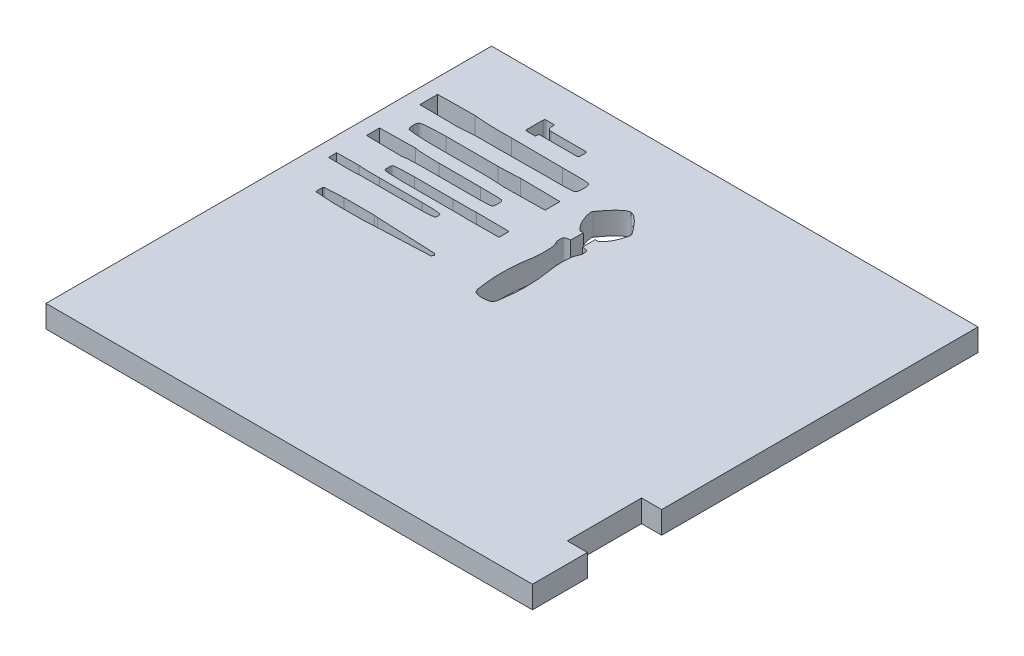
from build123d import *

# Parameters (mm, degrees)
SKICA1_W                 = 655
SKICA1_H                 = 600
P_IDAT_VYSUNUT_M1_DEPTH  = 30
SKICA3_W                 = 54.082765628
SKICA3_H                 = 100
KONTROLA_100_DEPTH       = 31
ODEBRAT_VYSUNUT_M1_DEPTH = 31
SEKACE_DEPTH             = 31.0000001


with BuildPart() as part:
    # Skica1 → Přidat vysunutím1 (new body)
    with BuildSketch(Plane(origin=(0, 0, 0), x_dir=(1, 0, 0), z_dir=(0, 1, 0))):
        Rectangle(SKICA1_W, SKICA1_H)
    extrude(amount=P_IDAT_VYSUNUT_M1_DEPTH)

    # Skica3 → KONTROLA_100 (cut, through all)
    with BuildSketch(Plane(origin=(0, 30, 0), x_dir=(1, 0, 0), z_dir=(0, 1, 0))):
        with Locations((327.5, -175.970044555)):
            Rectangle(SKICA3_W, SKICA3_H)
    extrude(amount=-KONTROLA_100_DEPTH, mode=Mode.SUBTRACT)

    # Skica4 → Odebrat vysunutím1 (cut, through all)
    with BuildSketch(Plane(origin=(0, 30, 0), x_dir=(1, 0, 0), z_dir=(0, 1, 0))):
        with BuildLine():
            Line((-192.848768769, 245.152749842), (-193.232573401, 250.450660731))
            Line((-193.232573401, 250.450660731), (-204.547490515, 250.450660731))
            ThreePointArc((-204.547490515, 250.450660731), (-205.961704077, 249.864874293), (-206.547490515, 248.450660731))
            Line((-206.547490515, 248.450660731), (-206.547490515, 226.450660731))
            ThreePointArc((-206.547490515, 226.450660731), (-205.961704077, 225.036447168), (-204.547490515, 224.450660731))
            Line((-204.547490515, 224.450660731), (-193.239817853, 224.450660731))
            Line((-193.239817853, 224.450660731), (-192.649430044, 228.074810057))
            ThreePointArc((-192.649430044, 228.074810057), (-192.310211907, 228.67586043), (-191.662440489, 228.914025677))
            Line((-191.662440489, 228.914025677), (-141.547490515, 228.914025677))
            ThreePointArc((-141.547490515, 228.914025677), (-140.133276952, 229.499812115), (-139.547490515, 230.914025677))
            Line((-139.547490515, 230.914025677), (-139.547490515, 238.514025677))
            ThreePointArc((-139.547490515, 238.514025677), (-140.133276952, 239.92823924), (-141.547490515, 240.514025677))
            Line((-141.547490515, 240.514025677), (-187.861837872, 240.514025677))
            ThreePointArc((-187.861837872, 240.514025677), (-191.267246865, 241.852988995), (-192.848768769, 245.152749842))
        make_face()
        with BuildLine():
            Line((-48.034805533, 126.818260272), (-48.034805533, 144.024453782))
            Line((-48.034805533, 144.024453782), (-52.534805533, 144.024453782))
            add(Edge.make_bspline(
                [(-52.534805533, 144.024453782), (-56.789361957, 147.681596628), (-60.810249216, 153.578897942), (-63.758899874, 160.548435859), (-66.17143223, 167.249914625), (-66.43949138, 171.270801885), (-67.662912077, 173.386742316), (-63.36084318, 179.518992695), (-60.323127238, 183.519518286), (-56.069166733, 188.562300914), (-52.402960699, 192.554391929), (-48.920064427, 195.571006192), (-45.783712558, 198.048359078), (-44.218127472, 198.865828685), (-42.757145161, 199.448493187), (-41.262630134, 200.024453782), (-40.034805533, 200.024453782)],
                knots=[0, 0, 0, 0, 0.287040646, 0.36174563, 0.417318532, 0.43829661, 0.471451184, 0.527970852, 0.6634257, 0.729020879, 0.795088629, 0.875046582, 0.930973553, 0.962796243, 0.981966174, 1, 1, 1, 1], degree=3))
            add(Edge.make_bspline(
                [(-27.534805533, 144.024453782), (-23.28024911, 147.681596628), (-19.25936185, 153.578897942), (-16.310711193, 160.548435859), (-13.898178837, 167.249914625), (-13.630119686, 171.270801885), (-12.406698989, 173.386742316), (-16.708767886, 179.518992695), (-19.746483828, 183.519518286), (-24.000444333, 188.562300914), (-27.666650367, 192.554391929), (-31.14954664, 195.571006192), (-34.285898508, 198.048359078), (-35.851483594, 198.865828685), (-37.312465906, 199.448493187), (-38.806980932, 200.024453782), (-40.034805533, 200.024453782)],
                knots=[0, 0, 0, 0, 0.287040646, 0.36174563, 0.417318532, 0.43829661, 0.471451184, 0.527970852, 0.6634257, 0.729020879, 0.795088629, 0.875046582, 0.930973553, 0.962796243, 0.981966174, 1, 1, 1, 1], degree=3))
            Line((-27.534805533, 144.024453782), (-32.034805533, 144.024453782))
            Line((-32.034805533, 144.024453782), (-32.034805533, 126.818260272))
            add(Edge.make_bspline(
                [(-40.034805533, 0.024453782), (-35.976200354, -0.069267822), (-31.016533091, 1.330611977), (-29.216834789, 2.41919939), (-26.823159008, 5.220573734), (-25.778403053, 13.102219758), (-24.418012978, 23.808208807), (-23.496224831, 36.678374415), (-23.794838184, 50.569648615), (-24.350993767, 62.887187031), (-26.52570747, 75.75021444), (-28.269214326, 87.373647016), (-28.229626604, 100.241736791), (-27.479464668, 110.266407005), (-23.944342803, 116.714367094), (-23.845823145, 120.668514538), (-23.731584907, 124.639909226), (-25.482847387, 125.635589086), (-27.465428975, 126.612992724), (-31.035028361, 126.865200815), (-31.753621576, 126.828533659), (-32.034805533, 126.818260272)],
                knots=[0, 0, 0, 0, 0.061122155, 0.06523853, 0.079152994, 0.136803937, 0.218949046, 0.31606897, 0.392132497, 0.506227541, 0.569555453, 0.661259712, 0.747779892, 0.836871577, 0.864437331, 0.888074676, 0.92301319, 0.927486047, 0.939519235, 0.972540283, 0.97818806, 0.97818806, 0.97818806, 0.97818806], degree=3))
            add(Edge.make_bspline(
                [(-40.034805533, 0.024453782), (-44.093410713, -0.069267822), (-49.053077975, 1.330611977), (-50.852776278, 2.41919939), (-53.246452059, 5.220573734), (-54.291208014, 13.102219758), (-55.651598088, 23.808208807), (-56.573386235, 36.678374415), (-56.274772882, 50.569648615), (-55.7186173, 62.887187031), (-53.543903596, 75.75021444), (-51.800396741, 87.373647016), (-51.839984463, 100.241736791), (-52.590146398, 110.266407005), (-56.125268263, 116.714367094), (-56.223787922, 120.668514538), (-56.33802616, 124.639909226), (-54.586763679, 125.635589086), (-52.604182092, 126.612992724), (-49.034582706, 126.865200815), (-48.315989491, 126.828533659), (-48.034805533, 126.818260272)],
                knots=[0, 0, 0, 0, 0.061122155, 0.06523853, 0.079152994, 0.136803937, 0.218949046, 0.31606897, 0.392132497, 0.506227541, 0.569555453, 0.661259712, 0.747779892, 0.836871577, 0.864437331, 0.888074676, 0.92301319, 0.927486047, 0.939519235, 0.972540283, 0.97818806, 0.97818806, 0.97818806, 0.97818806], degree=3))
        make_face()
    extrude(amount=-ODEBRAT_VYSUNUT_M1_DEPTH, mode=Mode.SUBTRACT)

    # Skica5 → sekace (cut, through all)
    with BuildSketch(Plane(origin=(0, 30, 0), x_dir=(1, 0, 0), z_dir=(0, 1, 0))):
        with BuildLine():
            Line((-307.5, 183.466765274), (-307.5, 207.466765274))
            Line((-307.5, 207.466765274), (-257.5, 207.966765274))
            add(Edge.make_bspline(
                [(-257.5, 207.966765274), (-256.825170626, 207.973513567), (-246.950522021, 206.764512553), (-227.064372425, 206.19378827), (-216.209974013, 206.354501395), (-213.967763147, 206.418233644), (-206.879336, 206.366765274)],
                knots=[0, 0, 0, 0, 0.125665232, 0.229420079, 0.35147339, 1, 1, 1, 1], degree=3))
            Line((-206.879336, 206.366765274), (-138.017362165, 205.866765274))
            add(Edge.make_bspline(
                [(-138.017362165, 205.866765274), (-133.169322065, 205.831564133), (-122.851497032, 205.849776458), (-114.403692314, 205.944210928), (-105.556283222, 205.527110902), (-101.069687153, 204.772167441), (-100.126636611, 202.640223078), (-99.690880365, 200.248371974), (-99.534870337, 197.955991178), (-99.472580107, 196.514504584), (-99.490820333, 195.466765274)],
                knots=[0, 0, 0, 0, 0.329374562, 0.579022363, 0.753141124, 0.824270148, 0.863456886, 0.895145303, 0.938345002, 1, 1, 1, 1], degree=3))
            add(Edge.make_bspline(
                [(-138.017362165, 185.066765274), (-133.169194271, 185.066765274), (-122.851542303, 185.096224094), (-114.40368493, 184.987285665), (-105.556283854, 185.406593773), (-101.069687099, 186.161348367), (-100.126636619, 188.293309749), (-99.690880362, 190.68515779), (-99.534870338, 192.977539748), (-99.472580107, 194.419025928), (-99.490820333, 195.466765274)],
                knots=[0, 0, 0, 0, 0.329374562, 0.579022363, 0.753141124, 0.824270148, 0.863456886, 0.895145303, 0.938345002, 1, 1, 1, 1], degree=3))
            Line((-138.017362165, 185.066765274), (-206.879336, 184.566765274))
            add(Edge.make_bspline(
                [(-257.5, 182.966765274), (-256.825170626, 182.96001698), (-246.950522021, 184.169017995), (-227.064372425, 184.739742278), (-216.209974013, 184.579029153), (-213.967763147, 184.515296903), (-206.879336, 184.566765274)],
                knots=[0, 0, 0, 0, 0.125665232, 0.229420079, 0.35147339, 1, 1, 1, 1], degree=3))
            Line((-257.5, 182.966765274), (-307.5, 183.466765274))
        make_face()
        with BuildLine():
            Line((-183.297177135, 145.138303204), (-253.1807847, 145.138303204))
            add(Edge.make_bspline(
                [(-253.1807847, 145.138303204), (-257.558680308, 145.138303204), (-266.875520035, 145.510894763), (-274.667851406, 145.781636134), (-282.349634131, 146.738047815), (-285.690593405, 147.134730067), (-286.731220064, 148.387412028), (-287.724289224, 150.296263597), (-287.930474819, 152.350246305), (-287.860553511, 153.504931237), (-287.970251974, 154.638303204)],
                knots=[0, 0, 0, 0, 0.329374562, 0.579022363, 0.753141124, 0.824270148, 0.863456886, 0.895145303, 0.938345002, 1, 1, 1, 1], degree=3))
            add(Edge.make_bspline(
                [(-253.1807847, 164.138303204), (-257.558680308, 164.138303204), (-266.875520035, 163.765711645), (-274.667851406, 163.494970275), (-282.349634131, 162.538558594), (-285.690593405, 162.141876342), (-286.731220064, 160.88919438), (-287.724289224, 158.980342812), (-287.930474819, 156.926360103), (-287.860553511, 155.771675172), (-287.970251974, 154.638303204)],
                knots=[0, 0, 0, 0, 0.329374562, 0.579022363, 0.753141124, 0.824270148, 0.863456886, 0.895145303, 0.938345002, 1, 1, 1, 1], degree=3))
            Line((-253.1807847, 164.138303204), (-183.297177135, 164.138303204))
            add(Edge.make_bspline(
                [(-153.840717735, 165.388303204), (-156.381018857, 165.42378045), (-158.152236711, 164.94571804), (-166.248765598, 164.647022936), (-173.508871514, 164.24758879), (-178.168829322, 164.138303204), (-183.297177135, 164.138303204)],
                knots=[0, 0, 0, 0, 0.194961343, 0.326122465, 0.480415491, 1, 1, 1, 1], degree=3))
            Line((-153.840717735, 165.388303204), (-100.137962735, 164.638303204))
            Line((-100.137962735, 164.638303204), (-100.137962735, 144.638303204))
            Line((-100.137962735, 144.638303204), (-153.840717735, 143.888303204))
            add(Edge.make_bspline(
                [(-153.840717735, 143.888303204), (-156.381018857, 143.852825958), (-158.152236711, 144.330888369), (-166.248765598, 144.629583473), (-173.508871514, 145.029017619), (-178.168829322, 145.138303204), (-183.297177135, 145.138303204)],
                knots=[0, 0, 0, 0, 0.194961343, 0.326122465, 0.480415491, 1, 1, 1, 1], degree=3))
        make_face()
        with BuildLine():
            Line((-307.5, 111.637488957), (-307.5, 129.137488957))
            Line((-307.5, 129.137488957), (-259.5, 129.887488957))
            add(Edge.make_bspline(
                [(-259.5, 129.887488957), (-258.954393264, 129.897610162), (-256.387499572, 128.910341649), (-243.039415144, 128.445482987), (-235.468859797, 128.179849466), (-231.583969553, 128.146645276), (-226.137193305, 128.137488957)],
                knots=[0, 0, 0, 0, 0.125665232, 0.229420079, 0.35147339, 1, 1, 1, 1], degree=3))
            Line((-226.137193305, 128.137488957), (-170.453291679, 128.137488957))
            add(Edge.make_bspline(
                [(-170.453291679, 128.137488957), (-166.533017936, 128.137488957), (-158.101012388, 128.033226209), (-152.363390211, 127.988720018), (-144.443726456, 127.822186471), (-141.006793572, 127.309661392), (-140.011891948, 126.043422961), (-139.464451132, 124.941428745), (-139.342398212, 122.195238031), (-139.281371751, 123.598846618), (-139.301838676, 120.387488957)],
                knots=[0, 0, 0, 0, 0.329374562, 0.579022363, 0.753141124, 0.824270148, 0.863456886, 0.895145303, 0.938345002, 1, 1, 1, 1], degree=3))
            add(Edge.make_bspline(
                [(-170.453291679, 112.637488957), (-166.533017936, 112.637488957), (-158.101012388, 112.741751704), (-152.363390211, 112.786257896), (-144.443726456, 112.952791443), (-141.006793572, 113.465316522), (-140.011891948, 114.731554953), (-139.464451132, 115.833549169), (-139.342398212, 118.579739883), (-139.281371751, 117.176131296), (-139.301838676, 120.387488957)],
                knots=[0, 0, 0, 0, 0.329374562, 0.579022363, 0.753141124, 0.824270148, 0.863456886, 0.895145303, 0.938345002, 1, 1, 1, 1], degree=3))
            Line((-170.453291679, 112.637488957), (-226.137193305, 112.637488957))
            add(Edge.make_bspline(
                [(-259.5, 110.887488957), (-258.954393264, 110.877367752), (-256.387499572, 111.864636265), (-243.039415144, 112.329494927), (-235.468859797, 112.595128448), (-231.583969553, 112.628332638), (-226.137193305, 112.637488957)],
                knots=[0, 0, 0, 0, 0.125665232, 0.229420079, 0.35147339, 1, 1, 1, 1], degree=3))
            Line((-259.5, 110.887488957), (-307.5, 111.637488957))
        make_face()
        with BuildLine():
            Line((-99.48625027, 95.571644018), (-99.48625027, 82.071644018))
            Line((-99.48625027, 82.071644018), (-144.00481027, 81.671644018))
            add(Edge.make_bspline(
                [(-174.947812595, 82.021644018), (-167.923279872, 82.021644018), (-157.529643524, 81.896565918), (-146.160541985, 82.023738085), (-144.00481027, 81.671644018)],
                knots=[0, 0, 0, 0, 0.667267537, 1, 1, 1, 1], degree=3))
            Line((-174.947812595, 82.021644018), (-226.592960836, 82.021644018))
            add(Edge.make_bspline(
                [(-226.592960836, 82.021644018), (-230.228897125, 82.021644018), (-239.941818795, 82.200339613), (-243.816371479, 82.646648711), (-251.060662681, 82.646383186), (-254.166177225, 83.460134684), (-255.142954432, 84.24960962), (-255.459767915, 85.748739768), (-255.447455062, 87.291333593), (-255.503974584, 86.972861925), (-255.484998953, 88.821644018)],
                knots=[0, 0, 0, 0, 0.329374562, 0.579022363, 0.753141124, 0.824270148, 0.863456886, 0.895145303, 0.938345002, 1, 1, 1, 1], degree=3))
            add(Edge.make_bspline(
                [(-226.592960836, 95.621644018), (-229.821651085, 95.502666203), (-240.086085717, 95.485096316), (-243.792840424, 94.989764676), (-251.062677176, 94.997493388), (-254.166006699, 94.183103532), (-255.142980808, 93.393686121), (-255.459758853, 91.89454562), (-255.447459444, 90.351955722), (-255.503974179, 90.670425992), (-255.484998953, 88.821644018)],
                knots=[0, 0, 0, 0, 0.329374562, 0.579022363, 0.753141124, 0.824270148, 0.863456886, 0.895145303, 0.938345002, 1, 1, 1, 1], degree=3))
            Line((-226.592960836, 95.621644018), (-174.947812595, 95.621644018))
            add(Edge.make_bspline(
                [(-174.947812595, 95.621644018), (-167.923279872, 95.621644018), (-157.529643524, 95.746722118), (-146.160541985, 95.619549951), (-144.00481027, 95.971644018)],
                knots=[0, 0, 0, 0, 0.667267537, 1, 1, 1, 1], degree=3))
            Line((-144.00481027, 95.971644018), (-99.48625027, 95.571644018))
        make_face()
        with BuildLine():
            Line((-307.5, 71.398013007), (-277.5, 71.648013007))
            add(Edge.make_bspline(
                [(-277.5, 71.648013007), (-275.267289342, 71.266167567), (-262.537274446, 70.816671023), (-252.817785278, 70.898013007), (-249.334132133, 70.898013007)],
                knots=[0, 0, 0, 0, 0.629859405, 1, 1, 1, 1], degree=3))
            Line((-249.334132133, 70.898013007), (-191.801116707, 70.898013007))
            add(Edge.make_bspline(
                [(-191.801116707, 70.898013007), (-184.887290558, 70.898013007), (-177.950617379, 70.718512935), (-174.306167556, 70.457262051), (-170.831530807, 70.156823535), (-167.829322857, 69.718002202), (-165.975004586, 69.11142714), (-165.597494276, 67.888801928), (-165.499839303, 67.369330455), (-165.492147868, 66.663227123), (-165.502139011, 65.898013007)],
                knots=[0, 0, 0, 0, 0.329374562, 0.579022363, 0.753141124, 0.824270148, 0.863456886, 0.895145303, 0.938345002, 1, 1, 1, 1], degree=3))
            add(Edge.make_bspline(
                [(-191.801116707, 60.898013007), (-188.958916108, 60.875802165), (-176.508243907, 61.08538127), (-174.541429864, 61.337480599), (-170.811389983, 61.639312347), (-167.831027765, 62.078014511), (-165.974740883, 62.684600312), (-165.597584874, 63.907223591), (-165.499795493, 64.426695798), (-165.492151917, 65.132798869), (-165.502139011, 65.898013007)],
                knots=[0, 0, 0, 0, 0.329374562, 0.579022363, 0.753141124, 0.824270148, 0.863456886, 0.895145303, 0.938345002, 1, 1, 1, 1], degree=3))
            Line((-191.801116707, 60.898013007), (-249.334132133, 60.898013007))
            add(Edge.make_bspline(
                [(-277.5, 60.148013007), (-275.267289342, 60.529858447), (-262.537274446, 60.97935499), (-252.817785278, 60.898013007), (-249.334132133, 60.898013007)],
                knots=[0, 0, 0, 0, 0.629859405, 1, 1, 1, 1], degree=3))
            Line((-277.5, 60.148013007), (-307.5, 60.398013007))
            Line((-307.5, 60.398013007), (-307.5, 71.398013007))
        make_face()
        with BuildLine():
            Line((-121.517560322, 17.157849468), (-124.017560322, 14.407849468))
            Line((-124.017560322, 14.407849468), (-204.772935954, 10.907849468))
            Line((-204.772935954, 10.907849468), (-208.742052111, 10.407849468))
            Line((-208.742052111, 10.407849468), (-249.872183186, 10.407849468))
            Line((-249.872183186, 10.407849468), (-274.956953154, 11.827742108))
            ThreePointArc((-274.956953154, 11.827742108), (-275.96240219, 12.295091255), (-276.372183186, 13.325344876))
            Line((-276.372183186, 13.325344876), (-276.372183186, 20.99035406))
            ThreePointArc((-276.372183186, 20.99035406), (-275.96240219, 22.020607681), (-274.956953154, 22.487956828))
            Line((-274.956953154, 22.487956828), (-249.872183186, 23.907849468))
            Line((-249.872183186, 23.907849468), (-208.742052111, 23.907849468))
            Line((-208.742052111, 23.907849468), (-204.772935954, 23.407849468))
            Line((-204.772935954, 23.407849468), (-124.017560322, 19.907849468))
            Line((-124.017560322, 19.907849468), (-121.517560322, 17.157849468))
        make_face()
    extrude(amount=-SEKACE_DEPTH, mode=Mode.SUBTRACT)


solid = part.part
